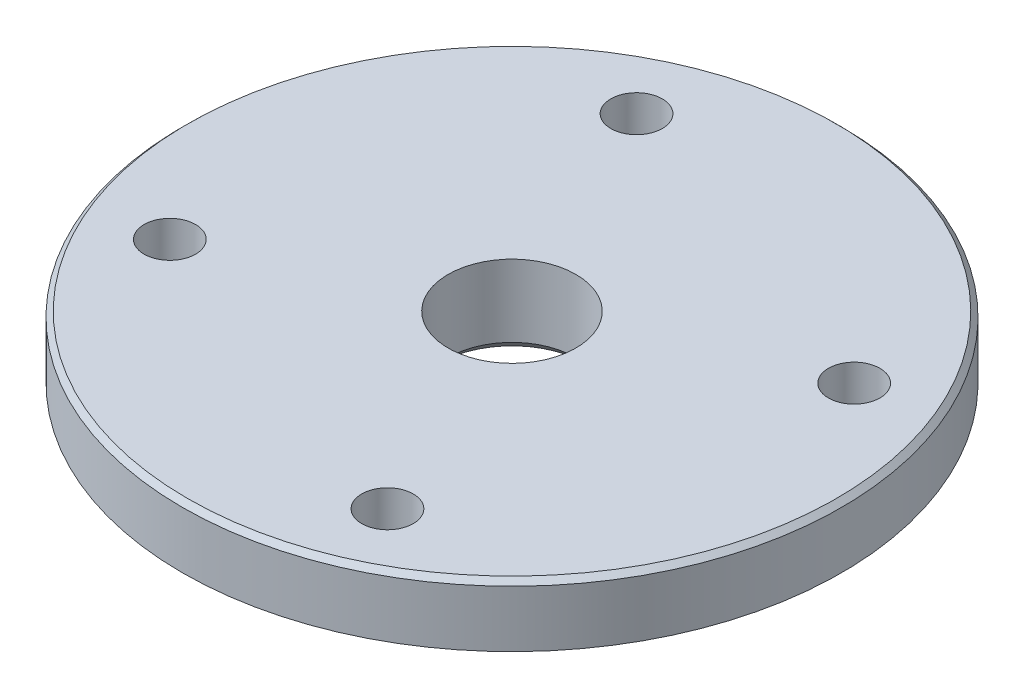
from build123d import *

# Parameters (mm, degrees)
CHANFRO1_SIZE                 = 0.5
FURO_ROSCADO_DE_M3X0_52_D     = 2.5
FURO_ROSCADO_DE_M3X0_52_DEPTH = 3.001
PADR_OCIRCULAR2_COUNT         = 4
CHANFRO2_SIZE                 = 0.2
CHANFRO3_SIZE                 = 0.25
FILETE3_R                     = 0.2


with BuildPart() as part:
    # Esboço1 → Revolução1 (revolve)
    with BuildSketch(Plane.XY):
        Polygon((3.1, 1.5), (3.1, -2.5), (9, -2.5), (9, -1.5), (16, -1.5), (16, 1.5), align=None)
    revolve(axis=Axis((0, 0, 0), (0, 1, 0)))

    # Chanfro1
    chanfro1_edges = [part.edges().sort_by_distance(p)[0] for p in [
        (-3.1, -2.5, 0),
    ]]
    chamfer(chanfro1_edges, length=CHANFRO1_SIZE)

    # Furo roscado de M3x0.52
    with Locations(Plane(origin=(0, 1.5, 0), x_dir=(1, 0, 0), z_dir=(0, 1, 0))):
        with Locations((11.328847338, 5.282728272)):
            furo_roscado_de_m3x0_52 = Hole(FURO_ROSCADO_DE_M3X0_52_D / 2, depth=FURO_ROSCADO_DE_M3X0_52_DEPTH)

    # PadrãoCircular2: Furo roscado de M3x0.52 ×4 about axis
    padr_ocircular2_axis = Axis((0, 0, 0), (0, 1, 0))
    for i in range(1, PADR_OCIRCULAR2_COUNT):
        add(furo_roscado_de_m3x0_52.rotate(padr_ocircular2_axis, i * 360 / PADR_OCIRCULAR2_COUNT), mode=Mode.SUBTRACT)

    # Chanfro2
    chanfro2_edges = [part.edges().sort_by_distance(p)[0] for p in [
        (-9, -2.5, 0),
    ]]
    chamfer(chanfro2_edges, length=CHANFRO2_SIZE)

    # Chanfro3
    chanfro3_edges = [part.edges().sort_by_distance(p)[0] for p in [
        (-16, 1.5, 0),
    ]]
    chamfer(chanfro3_edges, length=CHANFRO3_SIZE)

    # Filete3
    filete3_edges = [part.edges().sort_by_distance(p)[0] for p in [
        (-9, -1.5, 0),
    ]]
    fillet(filete3_edges, radius=FILETE3_R)


solid = part.part
